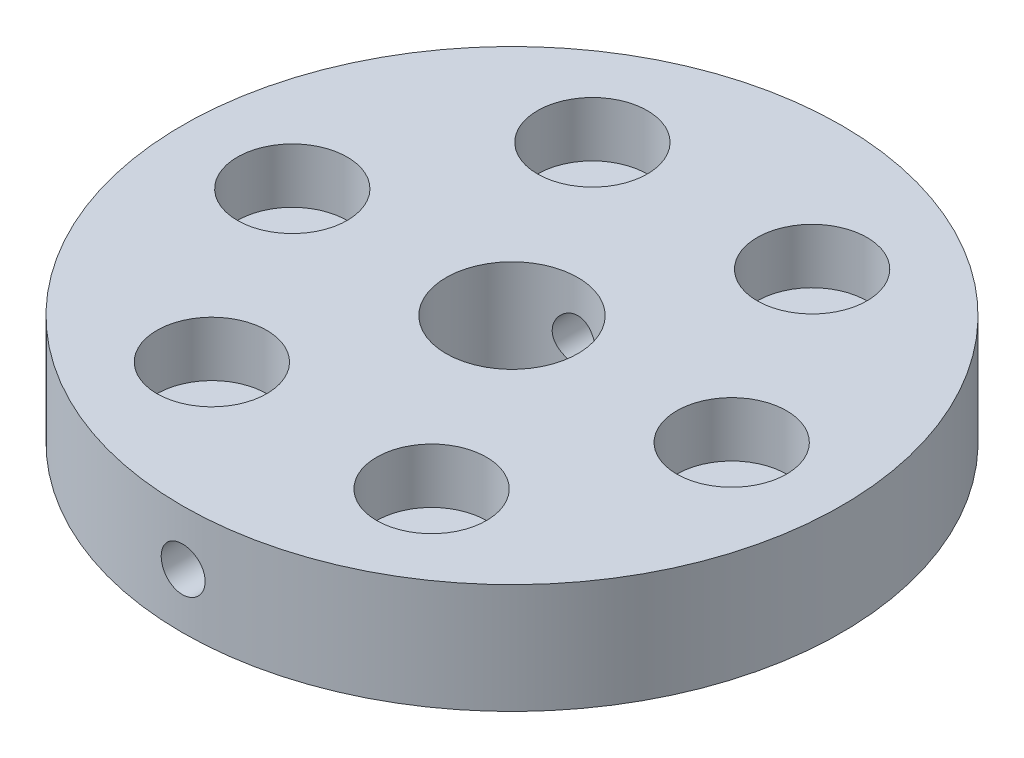
from build123d import *

# Parameters (mm, degrees)
SKETCH1_R               = 30
SKETCH1_R_2             = 2
SKETCH1_R_3             = 6
BOSS_EXTRUDE1_DEPTH     = 10
SKETCH2_R               = 2
CUT_EXTRUDE1_DEPTH      = 31
CUT_EXTRUDE1_DEPTH_BACK = 31
SKETCH3_R               = 5
CUT_EXTRUDE2_DEPTH      = 5


with BuildPart() as part:
    # Sketch1 → Boss-Extrude1 (new body)
    with BuildSketch(Plane(origin=(0, 0, 0), x_dir=(1, 0, 0), z_dir=(0, 1, 0))):
        Circle(SKETCH1_R)
        with Locations((20, 0)):
            Circle(SKETCH1_R_2, mode=Mode.SUBTRACT)
        with Locations((10, -17.320508076)):
            Circle(SKETCH1_R_2, mode=Mode.SUBTRACT)
        with Locations((-10, -17.320508076)):
            Circle(SKETCH1_R_2, mode=Mode.SUBTRACT)
        with Locations((-20, 0)):
            Circle(SKETCH1_R_2, mode=Mode.SUBTRACT)
        with Locations((-10, 17.320508076)):
            Circle(SKETCH1_R_2, mode=Mode.SUBTRACT)
        with Locations((10, 17.320508076)):
            Circle(SKETCH1_R_2, mode=Mode.SUBTRACT)
        Circle(SKETCH1_R_3, mode=Mode.SUBTRACT)
    extrude(amount=BOSS_EXTRUDE1_DEPTH)

    # Sketch2 → Cut-Extrude1 (cut, two sides)
    with BuildSketch(Plane.XY) as cut_extrude1_sk:
        with Locations((0, 5)):
            Circle(SKETCH2_R)
    extrude(amount=CUT_EXTRUDE1_DEPTH, mode=Mode.SUBTRACT)
    extrude(cut_extrude1_sk.sketch, amount=-CUT_EXTRUDE1_DEPTH_BACK, mode=Mode.SUBTRACT)

    # Sketch3 → Cut-Extrude2 (cut)
    with BuildSketch(Plane(origin=(0, 10, 0), x_dir=(1, 0, 0), z_dir=(0, 1, 0))):
        with Locations((-10, 17.320508076)):
            Circle(SKETCH3_R)
        with Locations((10, 17.320508076)):
            Circle(SKETCH3_R)
        with Locations((20, 0)):
            Circle(SKETCH3_R)
        with Locations((10, -17.320508076)):
            Circle(SKETCH3_R)
        with Locations((-10, -17.320508076)):
            Circle(SKETCH3_R)
        with Locations((-20, 0)):
            Circle(SKETCH3_R)
    extrude(amount=-CUT_EXTRUDE2_DEPTH, mode=Mode.SUBTRACT)


solid = part.part
